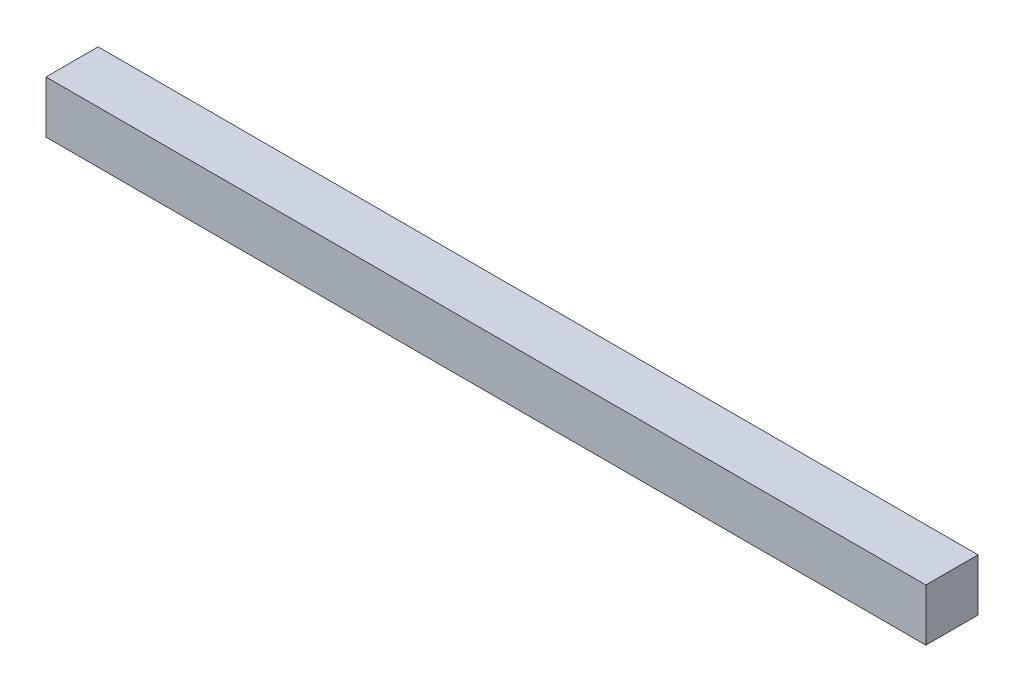
from build123d import *

# Parameters (mm, degrees)
SKETCH2_W           = 0.64
SKETCH2_H           = 0.64
BOSS_EXTRUDE1_DEPTH = 10.8


with BuildPart() as part:
    # Sketch2 → Boss-Extrude1 (new body)
    with BuildSketch(Plane(origin=(0, 0, 0), x_dir=(0, 0, -1), z_dir=(1, 0, 0))):
        Rectangle(SKETCH2_W, SKETCH2_H)
    extrude(amount=BOSS_EXTRUDE1_DEPTH)


solid = part.part
